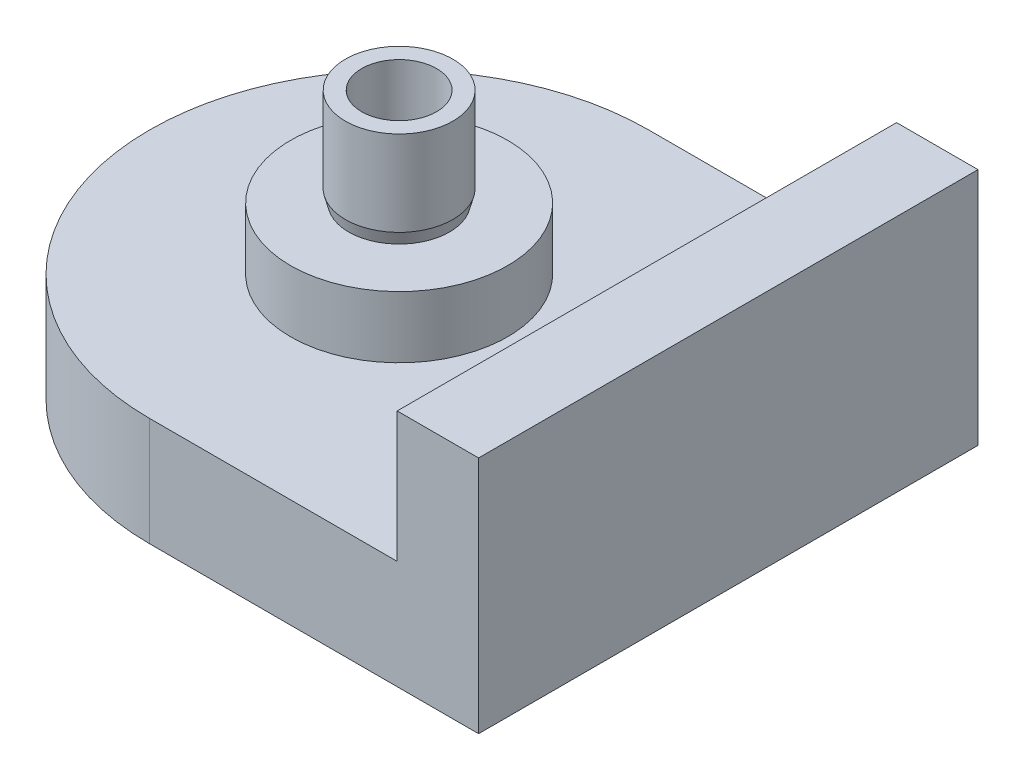
from build123d import *

# Parameters (mm, degrees)
SKETCH1_R           = 11.5
BOSS_EXTRUDE1_DEPTH = 5
SKETCH2_R           = 5
BOSS_EXTRUDE2_DEPTH = 2.84
SKETCH3_R           = 2.475
SKETCH3_R_2         = 1.725
BOSS_EXTRUDE3_DEPTH = 4.5
SKETCH4_R           = 1.8
CUT_EXTRUDE1_DEPTH  = 8.84
SKETCH5_OUTSIDE_W   = 33.03
SKETCH5_OUTSIDE_H   = 33.03
SKETCH5_OUTSIDE_R   = 2.320799334
CUT_EXTRUDE2_DEPTH  = 2
CUT_EXTRUDE2_DRAFT  = 15
BOSS_EXTRUDE4_DEPTH = 5
SKETCH7_W           = 1.1
SKETCH7_H           = 8
CUT_EXTRUDE3_DEPTH  = 10
SKETCH10_W          = 3.75
SKETCH10_H          = 23
BOSS_EXTRUDE5_DEPTH = 6


with BuildPart() as part:
    # Sketch1 → Boss-Extrude1 (new body)
    with BuildSketch(Plane(origin=(0, 0, 0), x_dir=(1, 0, 0), z_dir=(0, 1, 0))):
        with Locations(Location((0, 0, 0), (0, 0, 270))):  # turned: the seam where the file's is
            Circle(SKETCH1_R)
    extrude(amount=BOSS_EXTRUDE1_DEPTH)

    # Sketch2 → Boss-Extrude2 (add)
    with BuildSketch(Plane(origin=(0, 5, 0), x_dir=(1, 0, 0), z_dir=(0, 1, 0))):
        with Locations(Location((0, 0, 0), (0, 0, 270))):  # turned: the seam where the file's is
            Circle(SKETCH2_R)
    extrude(amount=BOSS_EXTRUDE2_DEPTH)

    # Sketch3 → Boss-Extrude3 (add)
    with BuildSketch(Plane(origin=(0, 7.84, 0), x_dir=(1, 0, 0), z_dir=(0, 1, 0))):
        with Locations(Location((0, 0, 0), (0, 0, 270))):  # turned: the seam where the file's is
            Circle(SKETCH3_R)
        with Locations(Location((0, 0, 0), (0, 0, 270))):  # turned: the seam where the file's is
            Circle(SKETCH3_R_2, mode=Mode.SUBTRACT)
    extrude(amount=BOSS_EXTRUDE3_DEPTH)

    # Sketch4 → Cut-Extrude1 (cut, through all)
    with BuildSketch(Plane(origin=(0, 7.84, 0), x_dir=(1, 0, 0), z_dir=(0, 1, 0))):
        with Locations(Location((0, 0, 0), (0, 0, 270))):  # turned: the seam where the file's is
            Circle(SKETCH4_R)
    extrude(amount=-CUT_EXTRUDE1_DEPTH, mode=Mode.SUBTRACT)


with BuildPart() as cut_extrude2_tool:
    # Sketch5 outside → Cut-Extrude2 (with draft: the straight prism first)
    with BuildSketch(Plane(origin=(0, 7.84, 0), x_dir=(1, 0, 0), z_dir=(0, 1, 0))):
        Rectangle(SKETCH5_OUTSIDE_W, SKETCH5_OUTSIDE_H)
        Circle(SKETCH5_OUTSIDE_R, mode=Mode.SUBTRACT)
    extrude(amount=CUT_EXTRUDE2_DEPTH)
    # Cut-Extrude2: the draft: its side faces are tilted about the plane it starts from
    cut_extrude2_sides = [cut_extrude2_tool.faces().sort_by_distance(p)[0] for p in [
        (0, 8.84, 16.515),
        (16.515, 8.84, 0),
        (0, 8.84, -16.515),
        (-16.515, 8.84, 0),
        (-2.320799334, 8.84, 0),
    ]]
    draft(cut_extrude2_sides, Plane(origin=(0, 7.84, 0), x_dir=(1, 0, 0), z_dir=(0, 1, 0)), CUT_EXTRUDE2_DRAFT)


with BuildPart() as part_1:
    add(part.part)

    # Cut-Extrude2: cut by cut_extrude2_tool
    add(cut_extrude2_tool.part, mode=Mode.SUBTRACT)

    # Sketch6 → Boss-Extrude4 (add)
    with BuildSketch(Plane.XZ):
        with BuildLine():
            Line((0, -10.147230248), (0, -11.5))
            Line((0, -11.5), (15.160269884, -11.5))
            Line((15.160269884, -11.5), (15.160269884, 11.5))
            Line((15.160269884, 11.5), (0, 11.5))
            Line((0, 11.5), (0, 10.147230248))
            ThreePointArc((0, 10.147230248), (10.147230248, 0), (0, -10.147230248))
        make_face()
    extrude(amount=-BOSS_EXTRUDE4_DEPTH)

    # Sketch7 → Cut-Extrude3 (cut)
    with BuildSketch(Plane(origin=(0, 5, 0), x_dir=(1, 0, 0), z_dir=(0, 1, 0))):
        with Locations((10.860269884, 0)):
            Rectangle(SKETCH7_W, SKETCH7_H)
    extrude(amount=-CUT_EXTRUDE3_DEPTH, mode=Mode.SUBTRACT)

    # Sketch10 → Boss-Extrude5 (add)
    with BuildSketch(Plane(origin=(0, 5, 0), x_dir=(1, 0, 0), z_dir=(0, 1, 0))):
        with Locations((13.285269884, 0)):
            Rectangle(SKETCH10_W, SKETCH10_H)
    extrude(amount=BOSS_EXTRUDE5_DEPTH)


solid = part_1.part
